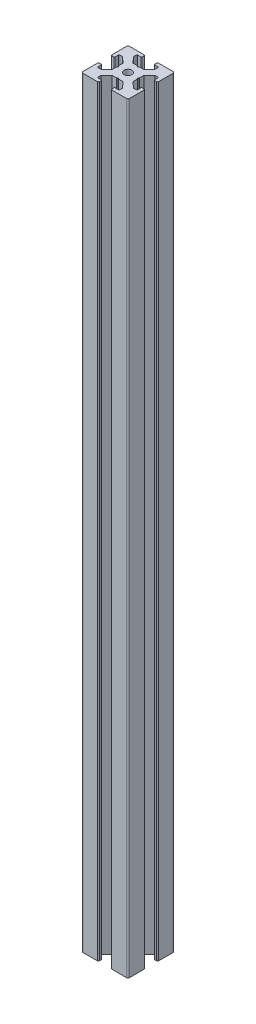
from build123d import *

# Parameters (mm, degrees)
BOSS_EXTRUDE1_DEPTH = 490
FILLET1_R           = 1
SKETCH4_R           = 2.5
CUT_EXTRUDE1_DEPTH  = 491
FILLET2_R           = 0.5


with BuildPart() as part:
    # Sketch3 → Boss-Extrude1 (new body)
    with BuildSketch(Plane(origin=(0, 0, 0), x_dir=(1, 0, 0), z_dir=(0, 1, 0))):
        with BuildLine():
            Line((11, 27.75), (11, 29.5))
            ThreePointArc((11, 29.5), (10.646446609, 29.646446609), (10.5, 30))
            Line((10.5, 30), (0, 30))
            Line((0, 30), (0, 19.5))
            ThreePointArc((0, 19.5), (0.353553391, 19.353553391), (0.5, 19))
            Line((0.5, 19), (2.25, 19))
            Line((2.25, 19), (2.25, 22))
            Line((2.25, 22), (4.5, 22))
            Line((4.5, 22), (8.25, 18.5))
            Line((8.25, 18.5), (8.25, 15.5))
            Line((8.25, 15.5), (8.75, 15))
            Line((8.75, 15), (8.25, 14.5))
            Line((8.25, 14.5), (8.25, 11.5))
            Line((8.25, 11.5), (4.5, 8))
            Line((4.5, 8), (2.25, 8))
            Line((2.25, 8), (2.25, 11))
            Line((2.25, 11), (0.5, 11))
            ThreePointArc((0.5, 11), (0.353553391, 10.646446609), (0, 10.5))
            Line((0, 10.5), (0, 0))
            Line((0, 0), (10.5, 0))
            ThreePointArc((10.5, 0), (10.646446609, 0.353553391), (11, 0.5))
            Line((11, 0.5), (11, 2.25))
            Line((11, 2.25), (8, 2.25))
            Line((8, 2.25), (8, 4.5))
            Line((8, 4.5), (11.5, 8.25))
            Line((11.5, 8.25), (14.5, 8.25))
            Line((14.5, 8.25), (15, 8.75))
            Line((15, 8.75), (15.5, 8.25))
            Line((15.5, 8.25), (18.5, 8.25))
            Line((18.5, 8.25), (22, 4.5))
            Line((22, 4.5), (22, 2.25))
            Line((22, 2.25), (19, 2.25))
            Line((19, 2.25), (19, 0.5))
            ThreePointArc((19, 0.5), (19.353553391, 0.353553391), (19.5, 0))
            Line((19.5, 0), (30, 0))
            Line((30, 0), (30, 10.5))
            ThreePointArc((30, 10.5), (29.646446609, 10.646446609), (29.5, 11))
            Line((29.5, 11), (27.75, 11))
            Line((27.75, 11), (27.75, 8))
            Line((27.75, 8), (25.5, 8))
            Line((25.5, 8), (21.75, 11.5))
            Line((21.75, 11.5), (21.75, 14.5))
            Line((21.75, 14.5), (21.25, 15))
            Line((21.25, 15), (21.75, 15.5))
            Line((21.75, 15.5), (21.75, 18.5))
            Line((21.75, 18.5), (25.5, 22))
            Line((25.5, 22), (27.75, 22))
            Line((27.75, 22), (27.75, 19))
            Line((27.75, 19), (29.5, 19))
            ThreePointArc((29.5, 19), (29.646446609, 19.353553391), (30, 19.5))
            Line((30, 19.5), (30, 30))
            Line((30, 30), (19.5, 30))
            ThreePointArc((19.5, 30), (19.353553391, 29.646446609), (19, 29.5))
            Line((19, 29.5), (19, 27.75))
            Line((19, 27.75), (22, 27.75))
            Line((22, 27.75), (22, 25.5))
            Line((22, 25.5), (18.5, 21.75))
            Line((18.5, 21.75), (15.5, 21.75))
            Line((15.5, 21.75), (15, 21.25))
            Line((15, 21.25), (14.5, 21.75))
            Line((14.5, 21.75), (11.5, 21.75))
            Line((11.5, 21.75), (8, 25.5))
            Line((8, 25.5), (8, 27.75))
            Line((8, 27.75), (11, 27.75))
        make_face()
    extrude(amount=BOSS_EXTRUDE1_DEPTH)

    # Fillet1
    fillet1_edges = [part.edges().sort_by_distance(p)[0] for p in [
        (30, 245, 0),
        (0, 245, 0),
        (0, 245, -30),
        (30, 245, -30),
    ]]
    fillet(fillet1_edges, radius=FILLET1_R)

    # Sketch4 → Cut-Extrude1 (cut, through all)
    with BuildSketch(Plane(origin=(0, 490, 0), x_dir=(1, 0, 0), z_dir=(0, 1, 0))):
        with Locations((15, 15)):
            Circle(SKETCH4_R)
    extrude(amount=-CUT_EXTRUDE1_DEPTH, mode=Mode.SUBTRACT)

    # Fillet2
    fillet2_edges = [part.edges().sort_by_distance(p)[0] for p in [
        (27.75, 245, -19),
        (27.75, 245, -22),
        (21.75, 245, -15.5),
        (21.75, 245, -14.5),
        (27.75, 245, -8),
        (27.75, 245, -11),
        (19, 245, -2.25),
        (22, 245, -2.25),
        (15.5, 245, -8.25),
        (14.5, 245, -8.25),
        (8, 245, -2.25),
        (11, 245, -2.25),
        (2.25, 245, -11),
        (2.25, 245, -8),
        (8.25, 245, -14.5),
        (8.25, 245, -15.5),
        (2.25, 245, -22),
        (2.25, 245, -19),
        (11, 245, -27.75),
        (8, 245, -27.75),
        (14.5, 245, -21.75),
        (15.5, 245, -21.75),
        (22, 245, -27.75),
        (19, 245, -27.75),
    ]]
    fillet(fillet2_edges, radius=FILLET2_R)


solid = part.part
